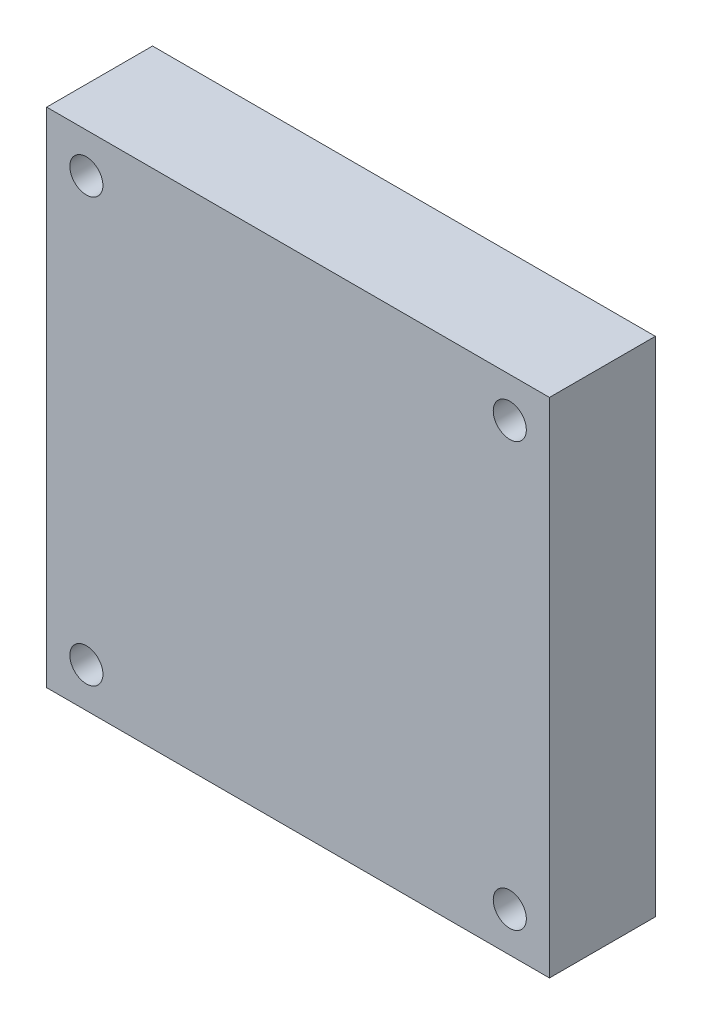
from build123d import *

# Parameters (mm, degrees)
SKETCH1_W               = 38
SKETCH1_H               = 38
BOSS_EXTRUDE1_DEPTH     = 4
SKETCH2_R               = 1.25
CUT_EXTRUDE1_DEPTH      = 9
MIRROR2_COPY_1_SKETCH_R = 1.25
MIRROR2_COPY_1_DEPTH    = 9


with BuildPart() as part:
    # Sketch1 → Boss-Extrude1 (new body, symmetric)
    with BuildSketch(Plane.XY):
        Rectangle(SKETCH1_W, SKETCH1_H)
    extrude(amount=BOSS_EXTRUDE1_DEPTH, both=True)

    # Sketch2 → Cut-Extrude1 (cut, through all)
    with BuildSketch(Plane.XY.offset(4)):
        with Locations((-16, 16)):
            Circle(SKETCH2_R)
    cut_extrude1 = extrude(amount=-CUT_EXTRUDE1_DEPTH, mode=Mode.SUBTRACT)

    # Mirror1: Cut-Extrude1 across plane
    add(cut_extrude1.mirror(Plane.ZX), mode=Mode.SUBTRACT)

    # Mirror2: Cut-Extrude1 across plane
    add(cut_extrude1.mirror(Plane(origin=(0, 0, 0), x_dir=(0, 0, 1), z_dir=(1, 0, 0))), mode=Mode.SUBTRACT)

    # Mirror2 copy 1 sketch → Mirror2 copy 1 (cut, through all)
    with BuildSketch(Plane(origin=(0, 0, 4), x_dir=(-1, 0, 0), z_dir=(0, 0, 1))):
        with Locations((-16, 16)):
            Circle(MIRROR2_COPY_1_SKETCH_R)
    extrude(amount=-MIRROR2_COPY_1_DEPTH, mode=Mode.SUBTRACT)


solid = part.part
